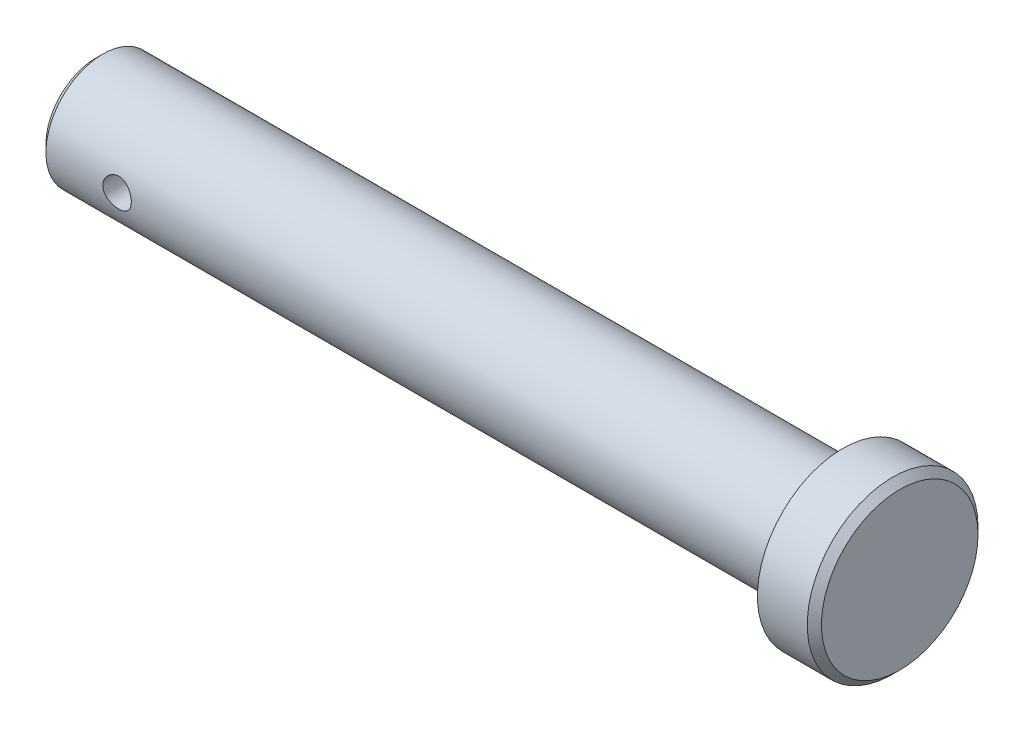
from build123d import *

# Parameters (mm, degrees)
SKETCH1_R               = 8
BOSS_EXTRUDE1_DEPTH     = 105
SKETCH1_4_R             = 12
BOSS_EXTRUDE2_DEPTH     = 8
CHAMFER1_SIZE           = 1
CUT_EXTRUDE1_DEPTH      = 14
CUT_EXTRUDE1_DEPTH_BACK = 20
SKETCH2_R               = 2


with BuildPart() as part:
    # Sketch1 → Boss-Extrude1 (new body)
    with BuildSketch(Plane(origin=(0, 0, 0), x_dir=(0, 0, -1), z_dir=(1, 0, 0))):
        Circle(SKETCH1_R)
    extrude(amount=-BOSS_EXTRUDE1_DEPTH)

    # Sketch1_4 → Boss-Extrude2 (add)
    with BuildSketch(Plane(origin=(0, 0, 0), x_dir=(0, 0, -1), z_dir=(1, 0, 0))):
        Circle(SKETCH1_4_R)
    extrude(amount=BOSS_EXTRUDE2_DEPTH)

    # Chamfer1
    chamfer1_edges = [part.edges().sort_by_distance(p)[0] for p in [
        (-105, 0, 8),
        (8, 0, 12),
    ]]
    chamfer(chamfer1_edges, length=CHAMFER1_SIZE)

    # Sketch2 → Cut-Extrude1 (cut, two sides: drawn at the far end of the back side and taken through both)
    with BuildSketch(Plane.XY.offset(-CUT_EXTRUDE1_DEPTH_BACK)):
        with Locations((-94, 0)):
            Circle(SKETCH2_R)
    extrude(amount=CUT_EXTRUDE1_DEPTH + CUT_EXTRUDE1_DEPTH_BACK, mode=Mode.SUBTRACT)


solid = part.part
